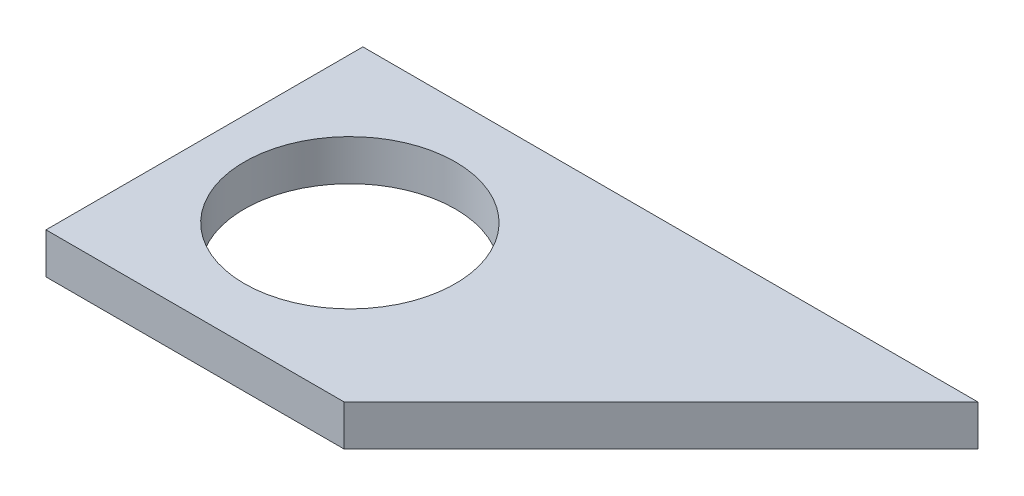
from build123d import *

# Parameters (mm, degrees)
SKETCH1_R           = 15
BOSS_EXTRUDE1_DEPTH = 5.8


with BuildPart() as part:
    # Sketch1 → Boss-Extrude1 (new body)
    with BuildSketch(Plane(origin=(0, 0, 0), x_dir=(1, 0, 0), z_dir=(0, 1, 0))):
        Polygon((42.4, 0), (87.45, 45.05), (52.797452229, 45.05), (0, 45.05), (0, 0), align=None)
        with Locations((20.73, 22.47)):
            Circle(SKETCH1_R, mode=Mode.SUBTRACT)
    extrude(amount=BOSS_EXTRUDE1_DEPTH)


solid = part.part
